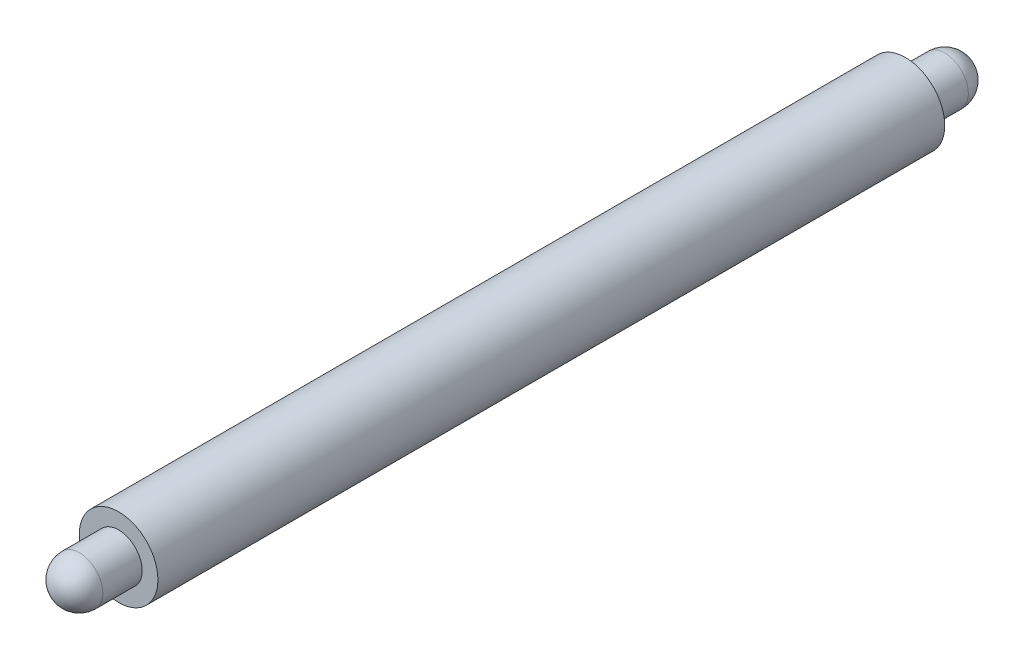
from build123d import *

# Parameters (mm, degrees)
SKETCH1_R           = 5
BOSS_EXTRUDE1_DEPTH = 100
SKETCH2_R           = 3
BOSS_EXTRUDE2_DEPTH = 8
SKETCH4_R           = 3
BOSS_EXTRUDE3_DEPTH = 8
FILLET1_R           = 3


with BuildPart() as part:
    # Sketch1 → Boss-Extrude1 (new body)
    with BuildSketch(Plane.XY):
        with Locations((-48.10405297, 10.230555556)):
            Circle(SKETCH1_R)
    extrude(amount=BOSS_EXTRUDE1_DEPTH)

    # Sketch2 → Boss-Extrude2 (add)
    with BuildSketch(Plane.XY.offset(100)):
        with Locations((-48.10405297, 10.230555556)):
            Circle(SKETCH2_R)
    extrude(amount=BOSS_EXTRUDE2_DEPTH)

    # Sketch4 → Boss-Extrude3 (add)
    with BuildSketch(Plane(origin=(0, 0, 0), x_dir=(-1, 0, 0), z_dir=(0, 0, -1))):
        with Locations((48.10405297, 10.230555556)):
            Circle(SKETCH4_R)
    extrude(amount=BOSS_EXTRUDE3_DEPTH)

    # Fillet1
    fillet1_edges = [part.edges().sort_by_distance(p)[0] for p in [
        (-45.10405297, 10.230555556, -8),
        (-51.10405297, 10.230555556, 108),
    ]]
    fillet(fillet1_edges, radius=FILLET1_R)


solid = part.part
